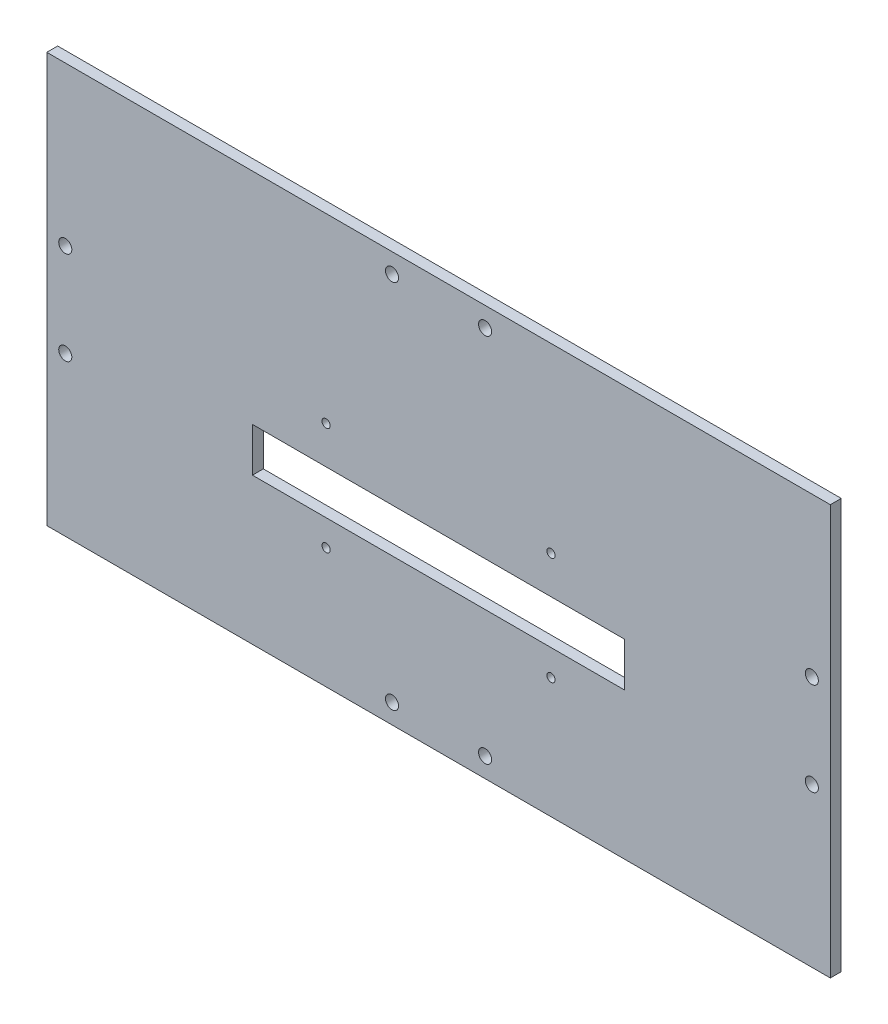
from build123d import *

# Parameters (mm, degrees)
SKETCH1_W           = 228.1936
SKETCH1_H           = 119.38
SKETCH1_R           = 1.905
SKETCH1_R_2         = 1.2
SKETCH1_W_2         = 108.4
SKETCH1_H_2         = 12.81
BOSS_EXTRUDE1_DEPTH = 3.175


with BuildPart() as part:
    # Sketch1 → Boss-Extrude1 (new body)
    with BuildSketch(Plane.XY):
        Rectangle(SKETCH1_W, SKETCH1_H)
        with Locations((-108.712, 13.5509)):
            Circle(SKETCH1_R, mode=Mode.SUBTRACT)
        with Locations((-108.712, -13.5509)):
            Circle(SKETCH1_R, mode=Mode.SUBTRACT)
        with Locations((108.712, -13.5509)):
            Circle(SKETCH1_R, mode=Mode.SUBTRACT)
        with Locations((108.712, 13.5509)):
            Circle(SKETCH1_R, mode=Mode.SUBTRACT)
        with Locations((-32.75, 6.761999938)):
            Circle(SKETCH1_R_2, mode=Mode.SUBTRACT)
        with Locations((32.75, 6.761999938)):
            Circle(SKETCH1_R_2, mode=Mode.SUBTRACT)
        with Locations((32.75, -24.5880001)):
            Circle(SKETCH1_R_2, mode=Mode.SUBTRACT)
        with Locations((-32.75, -24.5880001)):
            Circle(SKETCH1_R_2, mode=Mode.SUBTRACT)
        with Locations((-13.5509, 53.975)):
            Circle(SKETCH1_R, mode=Mode.SUBTRACT)
        with Locations((13.5509, 53.975)):
            Circle(SKETCH1_R, mode=Mode.SUBTRACT)
        with Locations((13.5509, -53.975)):
            Circle(SKETCH1_R, mode=Mode.SUBTRACT)
        with Locations((-13.5509, -53.975)):
            Circle(SKETCH1_R, mode=Mode.SUBTRACT)
        with Locations((0, -10.613)):
            Rectangle(SKETCH1_W_2, SKETCH1_H_2, mode=Mode.SUBTRACT)
    extrude(amount=BOSS_EXTRUDE1_DEPTH)


solid = part.part
